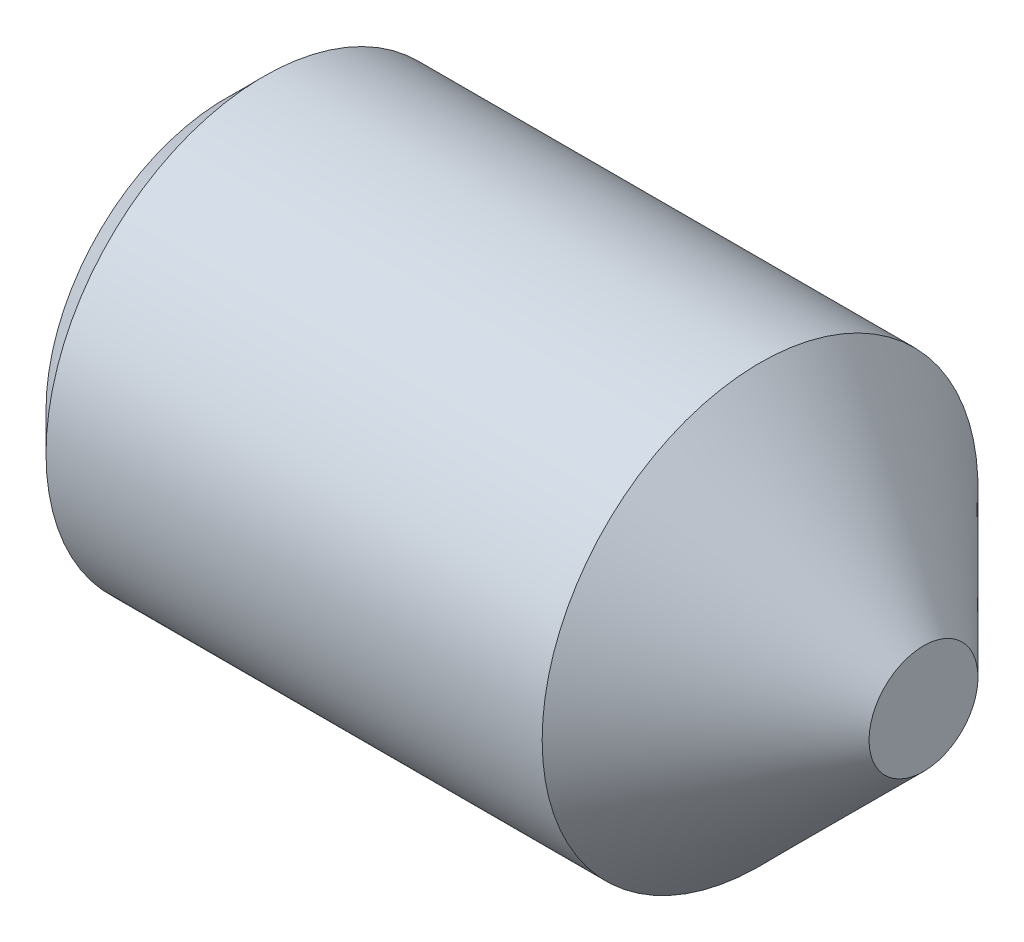
from build123d import *

# Parameters (mm, degrees)
HEXAGONSOCKET_DEPTH = 2


with BuildPart() as part:
    # Sketch1 → Base (revolve)
    with BuildSketch(Plane.XY):
        Polygon((0, 0), (8, 0), (8, 0.625), (6.125, 2.5), (0.433, 2.5), (0, 2.067), align=None)
    revolve(axis=Axis((-14.774129749, 0, 0), (1, 0, 0)))

    # Sketch2 → HexagonSocket (cut)
    with BuildSketch(Plane(origin=(0, 0.220293087, -0.139195271), x_dir=(0, 0, 1), z_dir=(-1, 0, 0))):
        Polygon((1.582570944, -0.220293087), (0.860883108, 1.029706913), (-0.582492565, 1.029706913), (-1.304180402, -0.220293087), (-0.582492565, -1.470293087), (0.860883108, -1.470293087), align=None)
    extrude(amount=-HEXAGONSOCKET_DEPTH, mode=Mode.SUBTRACT)

    # Sketch3 → Cut-Revolve (revolve, cut)
    with BuildSketch(Plane.XY):
        Polygon((2, 1.25), (2.721687836, 0), (2, 0), align=None)
    revolve(axis=Axis((2, 0, 0), (-1, 0, 0)), mode=Mode.SUBTRACT)


solid = part.part
